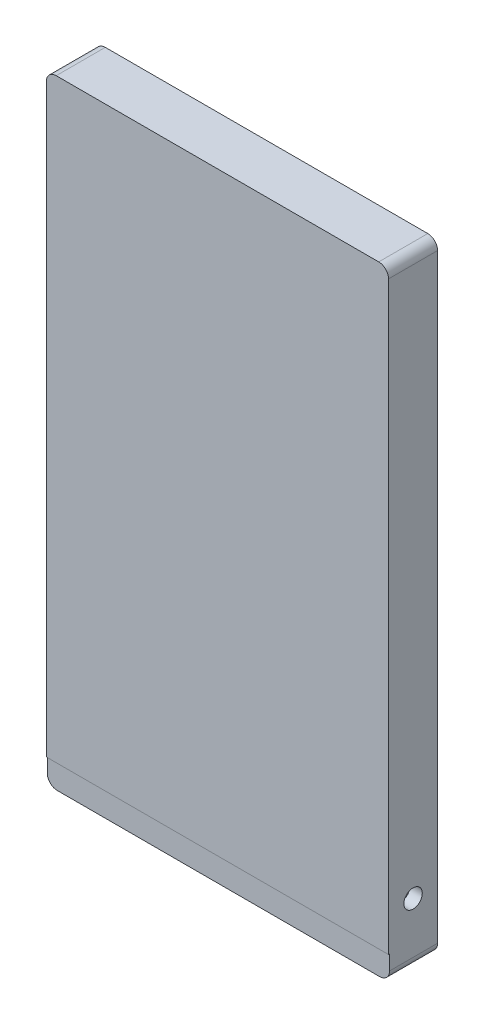
from build123d import *

# Parameters (mm, degrees)
SKETCH2_W           = 88.519
SKETCH2_H           = 153.924
BOSS_EXTRUDE2_DEPTH = 12.7
SKETCH2_6_W         = 82.169
SKETCH2_6_H         = 147.574
CUT_EXTRUDE1_DEPTH  = 10.16
SKETCH3_R           = 2.38125
CUT_EXTRUDE2_DEPTH  = 129.54
SKETCH4_W           = 88.519
SKETCH4_H           = 12.447800228
BOSS_EXTRUDE3_DEPTH = 6.35
FILLET1_R           = 2.54


with BuildPart() as part:
    # Sketch2 → Boss-Extrude2 (new body)
    with BuildSketch(Plane.XY):
        with Locations((41.0845, 73.787)):
            Rectangle(SKETCH2_W, SKETCH2_H)
    extrude(amount=BOSS_EXTRUDE2_DEPTH)

    # Sketch2_6 → Cut-Extrude1 (cut)
    with BuildSketch(Plane.XY):
        with Locations((41.0845, 73.787)):
            Rectangle(SKETCH2_6_W, SKETCH2_6_H)
    extrude(amount=CUT_EXTRUDE1_DEPTH, mode=Mode.SUBTRACT)

    # Sketch3 → Cut-Extrude2 (cut)
    with BuildSketch(Plane(origin=(85.344, 0, 0), x_dir=(0, 0, -1), z_dir=(1, 0, 0))):
        with Locations((-6.35, 6.217998886)):
            Circle(SKETCH3_R)
    extrude(amount=-CUT_EXTRUDE2_DEPTH, mode=Mode.SUBTRACT)

    # Sketch4 → Boss-Extrude3 (add)
    with BuildSketch(Plane.XZ.offset(3.175)):
        with Locations((41.0845, 6.223900114)):
            Rectangle(SKETCH4_W, SKETCH4_H)
    extrude(amount=BOSS_EXTRUDE3_DEPTH)

    # Fillet1
    fillet1_edges = [part.edges().sort_by_distance(p)[0] for p in [
        (85.344, -9.525, 6.223900114),
        (-3.175, -9.525, 6.223900114),
        (-3.175, 150.749, 6.35),
        (85.344, 150.749, 6.35),
    ]]
    fillet(fillet1_edges, radius=FILLET1_R)


solid = part.part
